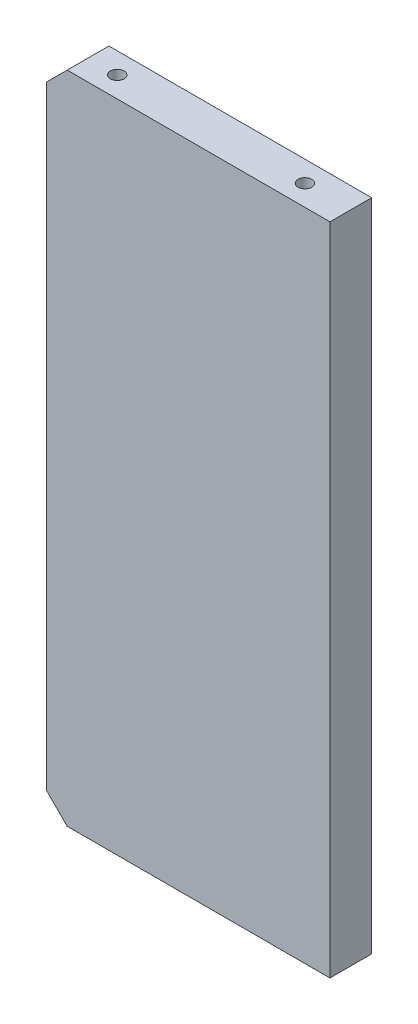
from build123d import *

# Parameters (mm, degrees)
SKETCH1_W                      = 68
SKETCH1_H                      = 157
BOSS_EXTRUDE1_DEPTH            = 10
M5X0_8_TAPPED_HOLE1_D          = 4.2
M5X0_8_TAPPED_HOLE1_DEPTH      = 12.4
M5X0_8_TAPPED_HOLE1_TIP        = 1.2618073
M4X0_7_TAPPED_HOLE1_AT_2_COUNT = 2
M4X0_7_TAPPED_HOLE1_AT_2_PITCH = 45
CHAMFER1_SIZE                  = 5


with BuildPart() as part:
    # Sketch1 → Boss-Extrude1 (new body)
    with BuildSketch(Plane.XY):
        with Locations((34, 0)):
            Rectangle(SKETCH1_W, SKETCH1_H)
    extrude(amount=-BOSS_EXTRUDE1_DEPTH)

    # M5x0.8 Tapped Hole1
    with Locations(Plane.ZY):
        with Locations((-5, 58.5), (-5, 0), (-5, -58.5)):
            Hole(M5X0_8_TAPPED_HOLE1_D / 2, depth=M5X0_8_TAPPED_HOLE1_DEPTH)
            with Locations((0, 0, -(M5X0_8_TAPPED_HOLE1_DEPTH + M5X0_8_TAPPED_HOLE1_TIP / 2))):  # 118° drill point
                Cone(0, M5X0_8_TAPPED_HOLE1_D / 2, M5X0_8_TAPPED_HOLE1_TIP, mode=Mode.SUBTRACT)

    # Sketch4 → M4x0.7 Tapped Hole1 (revolve, cut)
    with BuildSketch(Plane(origin=(12, 78.5, -5), x_dir=(0, 0, 1), z_dir=(1, 0, 0))):
        Polygon((0, 0), (0, 17.091420021), (1.65, 16.1), (1.65, 0), align=None)
    m4x0_7_tapped_hole1 = revolve(axis=Axis((12, 84.85, -5), (0, -1, 0)), mode=Mode.SUBTRACT)

    # M4x0.7 Tapped Hole1 at 2: M4x0.7 Tapped Hole1 ×2
    with Locations(*[(i * M4X0_7_TAPPED_HOLE1_AT_2_PITCH, 0, 0) for i in range(1, M4X0_7_TAPPED_HOLE1_AT_2_COUNT)]):
        add(m4x0_7_tapped_hole1, mode=Mode.SUBTRACT)

    # Mirror1: M4x0.7 Tapped Hole1 across plane
    add(m4x0_7_tapped_hole1.mirror(Plane.ZX), mode=Mode.SUBTRACT)

    # Mirror1 copy 1 sketch → Mirror1 copy 1 (revolve, cut)
    with BuildSketch(Plane(origin=(57, -78.5, -5), x_dir=(0, 0, 1), z_dir=(1, 0, 0))):
        Polygon((0, 0), (0, -17.091420021), (1.65, -16.1), (1.65, 0), align=None)
    revolve(axis=Axis((57, -84.85, -5), (0, -1, 0)), mode=Mode.SUBTRACT)

    # Chamfer1
    chamfer1_edges = [part.edges().sort_by_distance(p)[0] for p in [
        (0, -78.5, -5),
        (0, 78.5, -5),
    ]]
    chamfer(chamfer1_edges, length=CHAMFER1_SIZE)


solid = part.part
